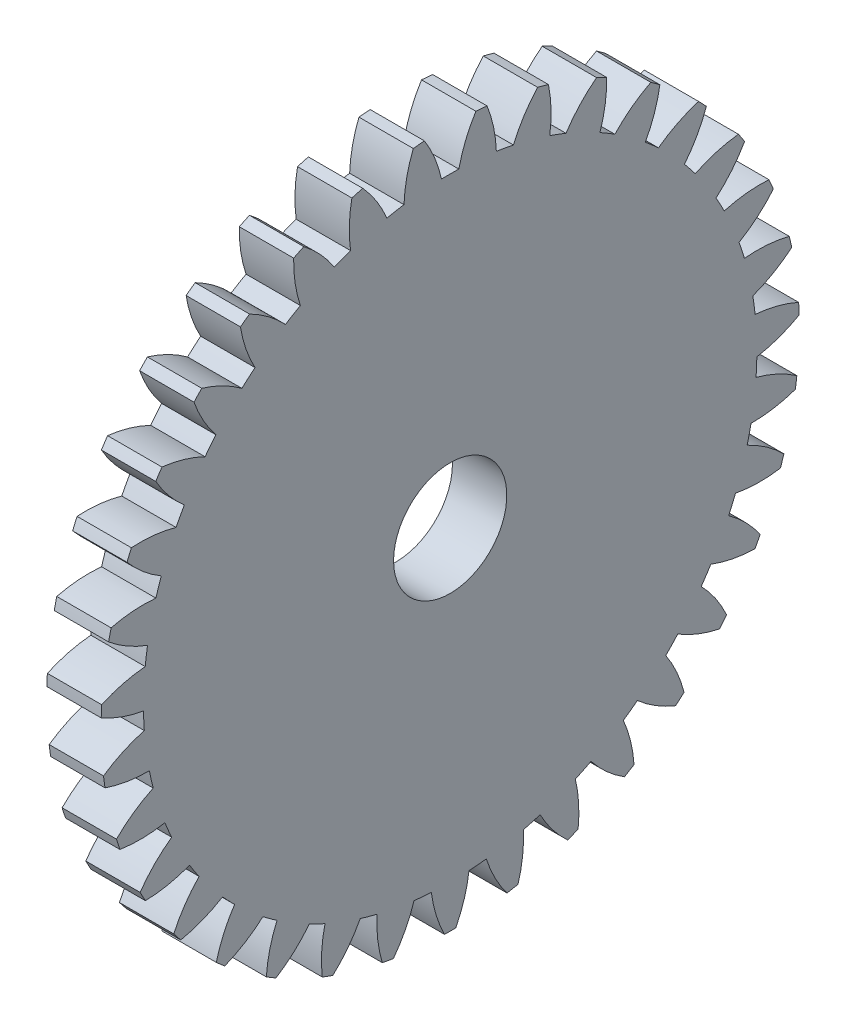
from build123d import *

# Parameters (mm, degrees)
BASPROSKE_W     = 3.048
BASPROSKE_H     = 19.579166667
TOOTHCUT_DEPTH  = 28.85637878
TEETHCUTS_COUNT = 35
TEETHCUTS_ANGLE = 349.714285714
BORSKE_R        = 3.175
BORE_DEPTH      = 50.8000508


with BuildPart() as part:
    # BasProSke → Base-Revolve (revolve)
    with BuildSketch(Plane(origin=(0, 0, 0), x_dir=(1, 0, 0), z_dir=(0, 1, 0)), mode=Mode.PRIVATE) as base_revolve_sk:
        with Locations((1.524, 9.789583334)):
            Rectangle(BASPROSKE_W, BASPROSKE_H)
    revolve(base_revolve_sk.sketch.rotate(Axis((-10, 0, 0), (1, 0, 0)), 180), axis=Axis((-10, 0, 0), (1, 0, 0)))

    # TooCutSke → ToothCut (cut, through all)
    with BuildSketch(Plane(origin=(0, 0, 0), x_dir=(0, 0, -1), z_dir=(1, 0, 0))):
        with BuildLine():
            ThreePointArc((0.487669335, 17.193118545), (0, 17.200033333), (-0.487669335, 17.193118545))
            ThreePointArc((-0.487669335, 17.193118545), (-0.870055892, 18.413729865), (-1.456703995, 19.550372059))
            ThreePointArc((-1.456703995, 19.550372059), (0, 19.604566667), (1.456703995, 19.550372059))
            ThreePointArc((1.456703995, 19.550372059), (0.870055892, 18.413729865), (0.487669335, 17.193118545))
        make_face()
    toothcut = extrude(amount=TOOTHCUT_DEPTH, mode=Mode.SUBTRACT)

    # TeethCuts: ToothCut ×35 about axis
    teethcuts_axis = Axis((-10, 0, 0), (1, 0, 0))
    for i in range(1, TEETHCUTS_COUNT):
        add(toothcut.rotate(teethcuts_axis, i * TEETHCUTS_ANGLE / (TEETHCUTS_COUNT - 1)), mode=Mode.SUBTRACT)

    # BorSke → Bore (cut, symmetric)
    with BuildSketch(Plane(origin=(0, 0, 0), x_dir=(0, 0, -1), z_dir=(1, 0, 0))):
        with Locations(Location((0, 0, 0), (0, 0, 180))):
            Circle(BORSKE_R)
    extrude(amount=BORE_DEPTH, both=True, mode=Mode.SUBTRACT)


solid = part.part
